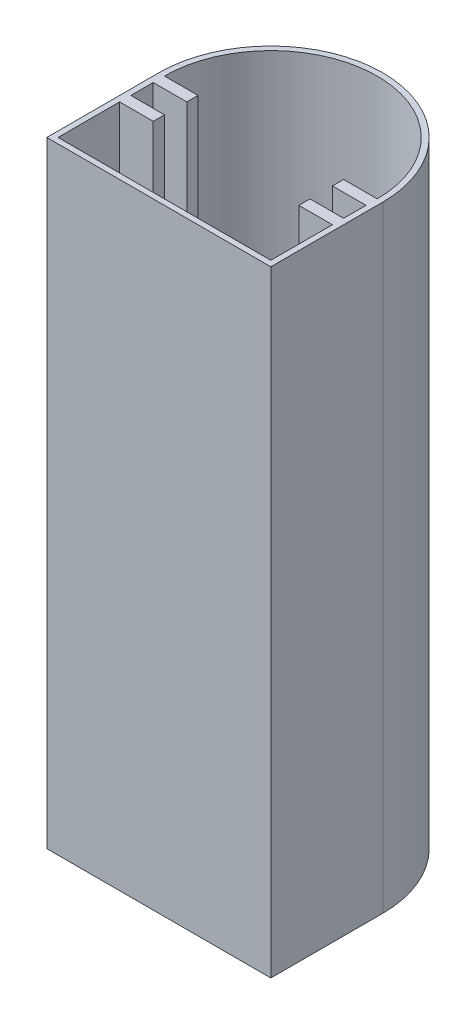
from build123d import *

# Parameters (mm, degrees)
BOSS_EXTRUDE1_DEPTH = 110
CUT_EXTRUDE1_DEPTH  = 109
SKETCH3_R           = 2.875
CUT_EXTRUDE2_DEPTH  = 5


with BuildPart() as part:
    # Sketch1 → Boss-Extrude1 (new body)
    with BuildSketch(Plane(origin=(0, 0, 0), x_dir=(1, 0, 0), z_dir=(0, 1, 0))):
        with BuildLine():
            Line((-38.883093525, -1.707733813), (1.116906475, -1.707733813))
            Line((1.116906475, -1.707733813), (1.116906475, 18.292266187))
            ThreePointArc((1.116906475, 18.292266187), (-18.883093525, 38.292266187), (-38.883093525, 18.292266187))
            Line((-38.883093525, 18.292266187), (-38.883093525, -1.707733813))
        make_face()
    extrude(amount=BOSS_EXTRUDE1_DEPTH)

    # Sketch2 → Cut-Extrude1 (cut)
    with BuildSketch(Plane(origin=(0, 110, 0), x_dir=(1, 0, 0), z_dir=(0, 1, 0))):
        with BuildLine():
            Line((-37.883093525, 16.292266187), (-37.883093525, 12.292266187))
            Line((-37.883093525, 12.292266187), (-31.883093525, 12.292266187))
            Line((-31.883093525, 12.292266187), (-31.883093525, 10.292266187))
            Line((-31.883093525, 10.292266187), (-37.883093525, 10.292266187))
            Line((-37.883093525, 10.292266187), (-37.883093525, -0.707733813))
            Line((-37.883093525, -0.707733813), (0.116906475, -0.707733813))
            Line((0.116906475, -0.707733813), (0.116906475, 10.292266187))
            Line((0.116906475, 10.292266187), (-5.883093525, 10.292266187))
            Line((-5.883093525, 10.292266187), (-5.883093525, 12.292266187))
            Line((-5.883093525, 12.292266187), (0.116906475, 12.292266187))
            Line((0.116906475, 12.292266187), (0.116906475, 16.292266187))
            Line((0.116906475, 16.292266187), (-5.883093525, 16.292266187))
            Line((-5.883093525, 16.292266187), (-5.883093525, 18.292266187))
            Line((-5.883093525, 18.292266187), (0.116906475, 18.292266187))
            ThreePointArc((0.116906475, 18.292266187), (-18.883093525, 37.292266187), (-37.883093525, 18.292266187))
            Line((-37.883093525, 18.292266187), (-31.883093525, 18.292266187))
            Line((-31.883093525, 18.292266187), (-31.883093525, 16.292266187))
            Line((-31.883093525, 16.292266187), (-37.883093525, 16.292266187))
        make_face()
    extrude(amount=-CUT_EXTRUDE1_DEPTH, mode=Mode.SUBTRACT)

    # Sketch3 → Cut-Extrude2 (cut)
    with BuildSketch(Plane.ZY.offset(38.883093525)):
        with Locations((-4.958932854, 55)):
            Circle(SKETCH3_R)
    extrude(amount=-CUT_EXTRUDE2_DEPTH, mode=Mode.SUBTRACT)


solid = part.part
